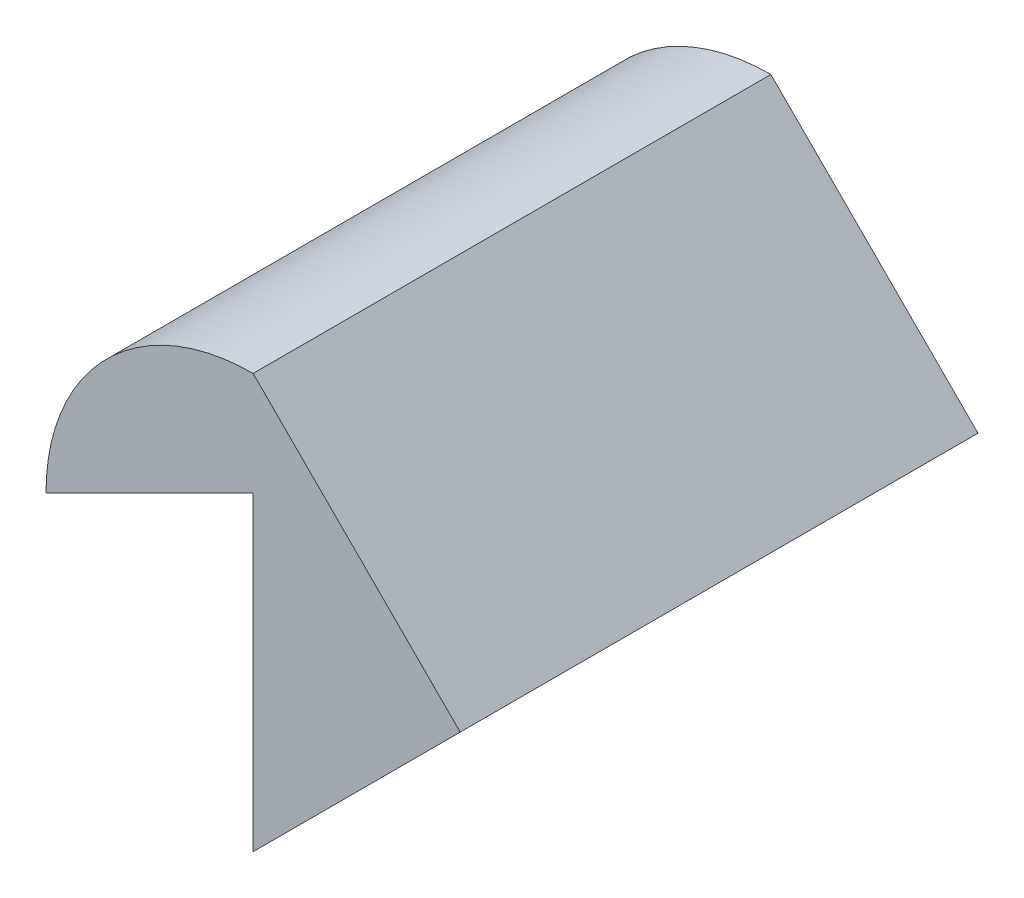
from build123d import *

# Parameters (mm, degrees)
BOSS_EXTRUDE1_DEPTH = 25


with BuildPart() as part:
    # Sketch1 → Boss-Extrude1 (new body)
    with BuildSketch(Plane.XY):
        with BuildLine():
            Line((-10, 5), (-10, -10))
            Line((-10, -10), (0, 0))
            Line((0, 0), (-10, 10))
            ThreePointArc((-10, 10), (-17.071067812, 7.071067812), (-20, 0))
            Line((-20, 0), (-10, 5))
        make_face()
    extrude(amount=BOSS_EXTRUDE1_DEPTH)


solid = part.part
